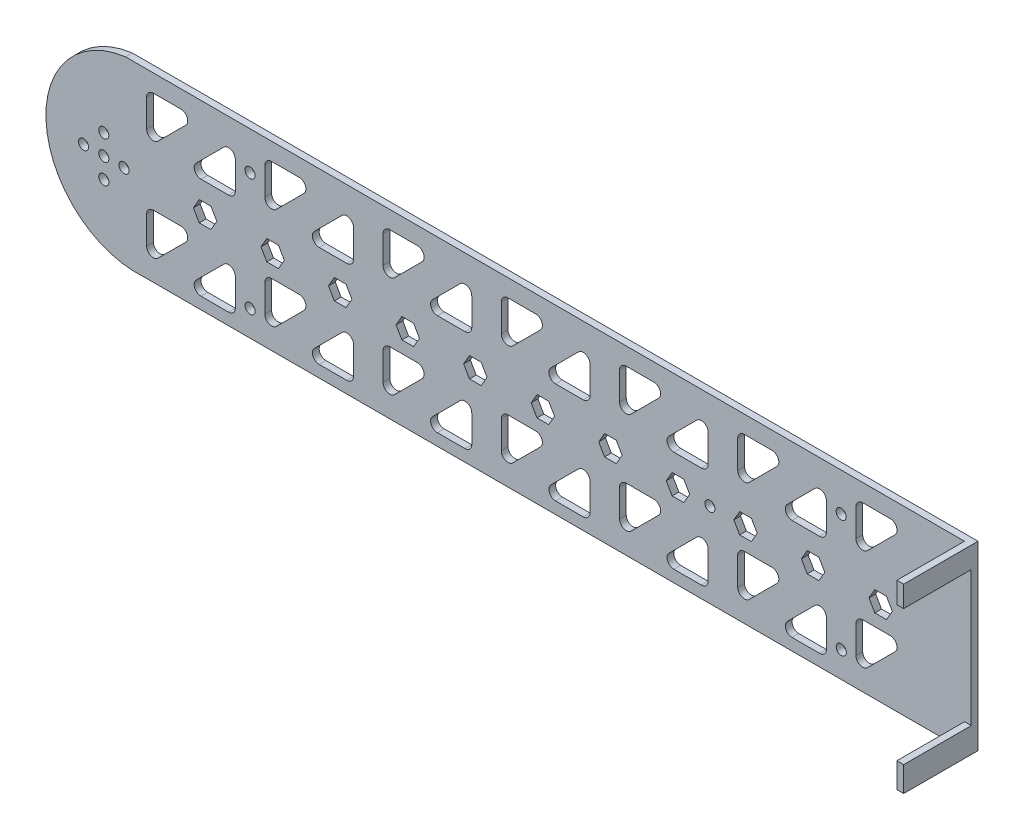
from build123d import *

# Parameters (mm, degrees)
IZIM1_R                     = 1.5
Y_KSEKLIK_EKSTR_ZYON2_DEPTH = 2
IZIM9_R                     = 1.5
KES_EKSTR_ZYON5_DEPTH       = 10
IZIM10_R                    = 1.5
KES_EKSTR_ZYON7_DEPTH       = 10
IZIM11_W                    = 22.917445978
IZIM11_H                    = 53.699619803
KES_EKSTR_ZYON8_DEPTH       = 10
IZIM12_W                    = 2
IZIM12_H                    = 53.699619803
Y_KSEKLIK_EKSTR_ZYON3_DEPTH = 20
KES_EKSTR_ZYON10_DEPTH      = 20


with BuildPart() as part:
    # Çizim1 → Yükseklik-Ekstrüzyon2 (new body)
    with BuildSketch(Plane.XY):
        with BuildLine():
            ThreePointArc((-123.68208832, 28.6803889), (-147.097650837, -0.85979795), (-118.162671893, -25.019230903))
            Line((-118.162671893, -25.019230903), (122.31562704, -25.019230903))
            Line((122.31562704, -25.019230903), (144.746839173, -25.019230903))
            ThreePointArc((144.746839173, -25.019230903), (146.161052735, -24.433444465), (146.746839173, -23.019230903))
            Line((146.746839173, -23.019230903), (146.746839173, -18.118237576))
            Line((146.746839173, -18.118237576), (127.216282083, -18.118237576))
            Line((127.216282083, -18.118237576), (126.706405407, 21.900803601))
            Line((126.706405407, 21.900803601), (146.706405407, 21.900803601))
            Line((146.706405407, 21.900803601), (146.706405407, 26.6803889))
            ThreePointArc((146.706405407, 26.6803889), (146.120618969, 28.094602463), (144.706405407, 28.6803889))
            Line((144.706405407, 28.6803889), (-123.68208832, 28.6803889))
        make_face()
        with BuildLine():
            Line((-117.432950192, -16.684982837), (-117.432950192, -8.513409962))
            ThreePointArc((-117.432950192, -8.513409962), (-116.847163754, -7.099196399), (-115.432950192, -6.513409962))
            Line((-115.432950192, -6.513409962), (-107.261377316, -6.513409962))
            ThreePointArc((-107.261377316, -6.513409962), (-105.413618251, -7.748043097), (-105.847163754, -9.927623524))
            Line((-105.847163754, -9.927623524), (-114.018736629, -18.099196399))
            ThreePointArc((-114.018736629, -18.099196399), (-116.198317056, -18.532741902), (-117.432950192, -16.684982837))
        make_face(mode=Mode.SUBTRACT)
        with BuildLine():
            Line((-102.756511954, -18.099196399), (-94.584939079, -9.927623524))
            ThreePointArc((-94.584939079, -9.927623524), (-92.405358652, -9.494078021), (-91.170725517, -11.341837086))
            Line((-91.170725517, -11.341837086), (-91.170725517, -19.513409962))
            ThreePointArc((-91.170725517, -19.513409962), (-91.756511954, -20.927623524), (-93.170725517, -21.513409962))
            Line((-93.170725517, -21.513409962), (-101.342298392, -21.513409962))
            ThreePointArc((-101.342298392, -21.513409962), (-103.190057457, -20.278776826), (-102.756511954, -18.099196399))
        make_face(mode=Mode.SUBTRACT)
        with BuildLine():
            Line((-82.432950192, -16.684982837), (-82.432950192, -8.513409962))
            ThreePointArc((-82.432950192, -8.513409962), (-81.847163754, -7.099196399), (-80.432950192, -6.513409962))
            Line((-80.432950192, -6.513409962), (-72.261377316, -6.513409962))
            ThreePointArc((-72.261377316, -6.513409962), (-70.413618251, -7.748043097), (-70.847163754, -9.927623524))
            Line((-70.847163754, -9.927623524), (-79.018736629, -18.099196399))
            ThreePointArc((-79.018736629, -18.099196399), (-81.198317056, -18.532741902), (-82.432950192, -16.684982837))
        make_face(mode=Mode.SUBTRACT)
        with BuildLine():
            Line((-67.756511954, -18.099196399), (-59.584939079, -9.927623524))
            ThreePointArc((-59.584939079, -9.927623524), (-57.405358652, -9.494078021), (-56.170725517, -11.341837086))
            Line((-56.170725517, -11.341837086), (-56.170725517, -19.513409962))
            ThreePointArc((-56.170725517, -19.513409962), (-56.756511954, -20.927623524), (-58.170725517, -21.513409962))
            Line((-58.170725517, -21.513409962), (-66.342298392, -21.513409962))
            ThreePointArc((-66.342298392, -21.513409962), (-68.190057457, -20.278776826), (-67.756511954, -18.099196399))
        make_face(mode=Mode.SUBTRACT)
        with BuildLine():
            Line((-47.432950192, -16.684982837), (-47.432950192, -8.513409962))
            ThreePointArc((-47.432950192, -8.513409962), (-46.847163754, -7.099196399), (-45.432950192, -6.513409962))
            Line((-45.432950192, -6.513409962), (-37.261377316, -6.513409962))
            ThreePointArc((-37.261377316, -6.513409962), (-35.413618251, -7.748043097), (-35.847163754, -9.927623524))
            Line((-35.847163754, -9.927623524), (-44.018736629, -18.099196399))
            ThreePointArc((-44.018736629, -18.099196399), (-46.198317056, -18.532741902), (-47.432950192, -16.684982837))
        make_face(mode=Mode.SUBTRACT)
        with BuildLine():
            Line((-32.756511954, -18.099196399), (-24.584939079, -9.927623524))
            ThreePointArc((-24.584939079, -9.927623524), (-22.405358652, -9.494078021), (-21.170725517, -11.341837086))
            Line((-21.170725517, -11.341837086), (-21.170725517, -19.513409962))
            ThreePointArc((-21.170725517, -19.513409962), (-21.756511954, -20.927623524), (-23.170725517, -21.513409962))
            Line((-23.170725517, -21.513409962), (-31.342298392, -21.513409962))
            ThreePointArc((-31.342298392, -21.513409962), (-33.190057457, -20.278776826), (-32.756511954, -18.099196399))
        make_face(mode=Mode.SUBTRACT)
        with BuildLine():
            Line((-12.432950192, -16.684982837), (-12.432950192, -8.513409962))
            ThreePointArc((-12.432950192, -8.513409962), (-11.847163754, -7.099196399), (-10.432950192, -6.513409962))
            Line((-10.432950192, -6.513409962), (-2.261377316, -6.513409962))
            ThreePointArc((-2.261377316, -6.513409962), (-0.413618251, -7.748043097), (-0.847163754, -9.927623524))
            Line((-0.847163754, -9.927623524), (-9.018736629, -18.099196399))
            ThreePointArc((-9.018736629, -18.099196399), (-11.198317056, -18.532741902), (-12.432950192, -16.684982837))
        make_face(mode=Mode.SUBTRACT)
        Polygon((-96.652716692, 0.01885212), (-98.388672632, -2.978889859), (-101.85277131, -2.974378905), (-103.580914048, 0.027874028), (-101.844958108, 3.025616007), (-98.38085943, 3.021105053), align=None, mode=Mode.SUBTRACT)
        Polygon((-76.652716692, 0.01885212), (-78.388672632, -2.978889859), (-81.85277131, -2.974378905), (-83.580914048, 0.027874028), (-81.844958108, 3.025616007), (-78.38085943, 3.021105053), align=None, mode=Mode.SUBTRACT)
        Polygon((-56.652716692, 0.01885212), (-58.388672632, -2.978889859), (-61.85277131, -2.974378905), (-63.580914048, 0.027874028), (-61.844958108, 3.025616007), (-58.38085943, 3.021105053), align=None, mode=Mode.SUBTRACT)
        Polygon((-36.652716692, 0.01885212), (-38.388672632, -2.978889859), (-41.85277131, -2.974378905), (-43.580914048, 0.027874028), (-41.844958108, 3.025616007), (-38.38085943, 3.021105053), align=None, mode=Mode.SUBTRACT)
        Polygon((-16.652716692, 0.01885212), (-18.388672632, -2.978889859), (-21.85277131, -2.974378905), (-23.580914048, 0.027874028), (-21.844958108, 3.025616007), (-18.38085943, 3.021105053), align=None, mode=Mode.SUBTRACT)
        Polygon((3.347283308, 0.01885212), (1.611327368, -2.978889859), (-1.85277131, -2.974378905), (-3.580914048, 0.027874028), (-1.844958108, 3.025616007), (1.61914057, 3.021105053), align=None, mode=Mode.SUBTRACT)
        with BuildLine():
            Line((2.243488046, -18.099196399), (10.415060921, -9.927623524))
            ThreePointArc((10.415060921, -9.927623524), (12.594641348, -9.494078021), (13.829274483, -11.341837086))
            Line((13.829274483, -11.341837086), (13.829274483, -19.513409962))
            ThreePointArc((13.829274483, -19.513409962), (13.243488046, -20.927623524), (11.829274483, -21.513409962))
            Line((11.829274483, -21.513409962), (3.657701608, -21.513409962))
            ThreePointArc((3.657701608, -21.513409962), (1.809942543, -20.278776826), (2.243488046, -18.099196399))
        make_face(mode=Mode.SUBTRACT)
        with BuildLine():
            Line((22.567049808, -16.684982837), (22.567049808, -8.513409962))
            ThreePointArc((22.567049808, -8.513409962), (23.152836246, -7.099196399), (24.567049808, -6.513409962))
            Line((24.567049808, -6.513409962), (32.738622684, -6.513409962))
            ThreePointArc((32.738622684, -6.513409962), (34.586381749, -7.748043097), (34.152836246, -9.927623524))
            Line((34.152836246, -9.927623524), (25.981263371, -18.099196399))
            ThreePointArc((25.981263371, -18.099196399), (23.801682944, -18.532741902), (22.567049808, -16.684982837))
        make_face(mode=Mode.SUBTRACT)
        with BuildLine():
            Line((37.243488046, -18.099196399), (45.415060921, -9.927623524))
            ThreePointArc((45.415060921, -9.927623524), (47.594641348, -9.494078021), (48.829274483, -11.341837086))
            Line((48.829274483, -11.341837086), (48.829274483, -19.513409962))
            ThreePointArc((48.829274483, -19.513409962), (48.243488046, -20.927623524), (46.829274483, -21.513409962))
            Line((46.829274483, -21.513409962), (38.657701608, -21.513409962))
            ThreePointArc((38.657701608, -21.513409962), (36.809942543, -20.278776826), (37.243488046, -18.099196399))
        make_face(mode=Mode.SUBTRACT)
        with BuildLine():
            Line((57.567049808, -16.684982837), (57.567049808, -8.513409962))
            ThreePointArc((57.567049808, -8.513409962), (58.152836246, -7.099196399), (59.567049808, -6.513409962))
            Line((59.567049808, -6.513409962), (67.738622684, -6.513409962))
            ThreePointArc((67.738622684, -6.513409962), (69.586381749, -7.748043097), (69.152836246, -9.927623524))
            Line((69.152836246, -9.927623524), (60.981263371, -18.099196399))
            ThreePointArc((60.981263371, -18.099196399), (58.801682944, -18.532741902), (57.567049808, -16.684982837))
        make_face(mode=Mode.SUBTRACT)
        with Locations((131.859799091, -22.099196399)):
            Circle(IZIM1_R, mode=Mode.SUBTRACT)
        with Locations((141.859799091, -22.099196399)):
            Circle(IZIM1_R, mode=Mode.SUBTRACT)
        with BuildLine():
            Line((72.243488046, -18.099196399), (80.415060921, -9.927623524))
            ThreePointArc((80.415060921, -9.927623524), (82.594641348, -9.494078021), (83.829274483, -11.341837086))
            Line((83.829274483, -11.341837086), (83.829274483, -19.513409962))
            ThreePointArc((83.829274483, -19.513409962), (83.243488046, -20.927623524), (81.829274483, -21.513409962))
            Line((81.829274483, -21.513409962), (73.657701608, -21.513409962))
            ThreePointArc((73.657701608, -21.513409962), (71.809942543, -20.278776826), (72.243488046, -18.099196399))
        make_face(mode=Mode.SUBTRACT)
        with BuildLine():
            Line((92.567049808, -16.684982837), (92.567049808, -8.513409962))
            ThreePointArc((92.567049808, -8.513409962), (93.152836246, -7.099196399), (94.567049808, -6.513409962))
            Line((94.567049808, -6.513409962), (102.738622684, -6.513409962))
            ThreePointArc((102.738622684, -6.513409962), (104.586381749, -7.748043097), (104.152836246, -9.927623524))
            Line((104.152836246, -9.927623524), (95.981263371, -18.099196399))
            ThreePointArc((95.981263371, -18.099196399), (93.801682944, -18.532741902), (92.567049808, -16.684982837))
        make_face(mode=Mode.SUBTRACT)
        Polygon((23.347283308, 0.01885212), (21.611327368, -2.978889859), (18.14722869, -2.974378905), (16.419085952, 0.027874028), (18.155041892, 3.025616007), (21.61914057, 3.021105053), align=None, mode=Mode.SUBTRACT)
        Polygon((43.347283308, 0.01885212), (41.611327368, -2.978889859), (38.14722869, -2.974378905), (36.419085952, 0.027874028), (38.155041892, 3.025616007), (41.61914057, 3.021105053), align=None, mode=Mode.SUBTRACT)
        Polygon((63.347283308, 0.01885212), (61.611327368, -2.978889859), (58.14722869, -2.974378905), (56.419085952, 0.027874028), (58.155041892, 3.025616007), (61.61914057, 3.021105053), align=None, mode=Mode.SUBTRACT)
        Polygon((83.347283308, 0.01885212), (81.611327368, -2.978889859), (78.14722869, -2.974378905), (76.419085952, 0.027874028), (78.155041892, 3.025616007), (81.61914057, 3.021105053), align=None, mode=Mode.SUBTRACT)
        Polygon((103.347283308, 0.01885212), (101.611327368, -2.978889859), (98.14722869, -2.974378905), (96.419085952, 0.027874028), (98.155041892, 3.025616007), (101.61914057, 3.021105053), align=None, mode=Mode.SUBTRACT)
        with BuildLine():
            Line((-102.756511954, 11.900803601), (-94.584939079, 20.072376476))
            ThreePointArc((-94.584939079, 20.072376476), (-92.405358652, 20.505921979), (-91.170725517, 18.658162914))
            Line((-91.170725517, 18.658162914), (-91.170725517, 10.486590038))
            ThreePointArc((-91.170725517, 10.486590038), (-91.756511954, 9.072376476), (-93.170725517, 8.486590038))
            Line((-93.170725517, 8.486590038), (-101.342298392, 8.486590038))
            ThreePointArc((-101.342298392, 8.486590038), (-103.190057457, 9.721223174), (-102.756511954, 11.900803601))
        make_face(mode=Mode.SUBTRACT)
        with BuildLine():
            Line((-67.756511954, 11.900803601), (-59.584939079, 20.072376476))
            ThreePointArc((-59.584939079, 20.072376476), (-57.405358652, 20.505921979), (-56.170725517, 18.658162914))
            Line((-56.170725517, 18.658162914), (-56.170725517, 10.486590038))
            ThreePointArc((-56.170725517, 10.486590038), (-56.756511954, 9.072376476), (-58.170725517, 8.486590038))
            Line((-58.170725517, 8.486590038), (-66.342298392, 8.486590038))
            ThreePointArc((-66.342298392, 8.486590038), (-68.190057457, 9.721223174), (-67.756511954, 11.900803601))
        make_face(mode=Mode.SUBTRACT)
        with BuildLine():
            Line((-32.756511954, 11.900803601), (-24.584939079, 20.072376476))
            ThreePointArc((-24.584939079, 20.072376476), (-22.405358652, 20.505921979), (-21.170725517, 18.658162914))
            Line((-21.170725517, 18.658162914), (-21.170725517, 10.486590038))
            ThreePointArc((-21.170725517, 10.486590038), (-21.756511954, 9.072376476), (-23.170725517, 8.486590038))
            Line((-23.170725517, 8.486590038), (-31.342298392, 8.486590038))
            ThreePointArc((-31.342298392, 8.486590038), (-33.190057457, 9.721223174), (-32.756511954, 11.900803601))
        make_face(mode=Mode.SUBTRACT)
        with BuildLine():
            Line((-117.432950192, 13.315017163), (-117.432950192, 21.486590038))
            ThreePointArc((-117.432950192, 21.486590038), (-116.847163754, 22.900803601), (-115.432950192, 23.486590038))
            Line((-115.432950192, 23.486590038), (-107.261377316, 23.486590038))
            ThreePointArc((-107.261377316, 23.486590038), (-105.413618251, 22.251956903), (-105.847163754, 20.072376476))
            Line((-105.847163754, 20.072376476), (-114.018736629, 11.900803601))
            ThreePointArc((-114.018736629, 11.900803601), (-116.198317056, 11.467258098), (-117.432950192, 13.315017163))
        make_face(mode=Mode.SUBTRACT)
        with BuildLine():
            Line((-82.432950192, 13.315017163), (-82.432950192, 21.486590038))
            ThreePointArc((-82.432950192, 21.486590038), (-81.847163754, 22.900803601), (-80.432950192, 23.486590038))
            Line((-80.432950192, 23.486590038), (-72.261377316, 23.486590038))
            ThreePointArc((-72.261377316, 23.486590038), (-70.413618251, 22.251956903), (-70.847163754, 20.072376476))
            Line((-70.847163754, 20.072376476), (-79.018736629, 11.900803601))
            ThreePointArc((-79.018736629, 11.900803601), (-81.198317056, 11.467258098), (-82.432950192, 13.315017163))
        make_face(mode=Mode.SUBTRACT)
        with BuildLine():
            Line((-47.432950192, 13.315017163), (-47.432950192, 21.486590038))
            ThreePointArc((-47.432950192, 21.486590038), (-46.847163754, 22.900803601), (-45.432950192, 23.486590038))
            Line((-45.432950192, 23.486590038), (-37.261377316, 23.486590038))
            ThreePointArc((-37.261377316, 23.486590038), (-35.413618251, 22.251956903), (-35.847163754, 20.072376476))
            Line((-35.847163754, 20.072376476), (-44.018736629, 11.900803601))
            ThreePointArc((-44.018736629, 11.900803601), (-46.198317056, 11.467258098), (-47.432950192, 13.315017163))
        make_face(mode=Mode.SUBTRACT)
        with BuildLine():
            Line((-12.432950192, 13.315017163), (-12.432950192, 21.486590038))
            ThreePointArc((-12.432950192, 21.486590038), (-11.847163754, 22.900803601), (-10.432950192, 23.486590038))
            Line((-10.432950192, 23.486590038), (-2.261377316, 23.486590038))
            ThreePointArc((-2.261377316, 23.486590038), (-0.413618251, 22.251956903), (-0.847163754, 20.072376476))
            Line((-0.847163754, 20.072376476), (-9.018736629, 11.900803601))
            ThreePointArc((-9.018736629, 11.900803601), (-11.198317056, 11.467258098), (-12.432950192, 13.315017163))
        make_face(mode=Mode.SUBTRACT)
        with BuildLine():
            Line((2.243488046, 11.900803601), (10.415060921, 20.072376476))
            ThreePointArc((10.415060921, 20.072376476), (12.594641348, 20.505921979), (13.829274483, 18.658162914))
            Line((13.829274483, 18.658162914), (13.829274483, 10.486590038))
            ThreePointArc((13.829274483, 10.486590038), (13.243488046, 9.072376476), (11.829274483, 8.486590038))
            Line((11.829274483, 8.486590038), (3.657701608, 8.486590038))
            ThreePointArc((3.657701608, 8.486590038), (1.809942543, 9.721223174), (2.243488046, 11.900803601))
        make_face(mode=Mode.SUBTRACT)
        with BuildLine():
            Line((37.243488046, 11.900803601), (45.415060921, 20.072376476))
            ThreePointArc((45.415060921, 20.072376476), (47.594641348, 20.505921979), (48.829274483, 18.658162914))
            Line((48.829274483, 18.658162914), (48.829274483, 10.486590038))
            ThreePointArc((48.829274483, 10.486590038), (48.243488046, 9.072376476), (46.829274483, 8.486590038))
            Line((46.829274483, 8.486590038), (38.657701608, 8.486590038))
            ThreePointArc((38.657701608, 8.486590038), (36.809942543, 9.721223174), (37.243488046, 11.900803601))
        make_face(mode=Mode.SUBTRACT)
        with BuildLine():
            Line((72.243488046, 11.900803601), (80.415060921, 20.072376476))
            ThreePointArc((80.415060921, 20.072376476), (82.594641348, 20.505921979), (83.829274483, 18.658162914))
            Line((83.829274483, 18.658162914), (83.829274483, 10.486590038))
            ThreePointArc((83.829274483, 10.486590038), (83.243488046, 9.072376476), (81.829274483, 8.486590038))
            Line((81.829274483, 8.486590038), (73.657701608, 8.486590038))
            ThreePointArc((73.657701608, 8.486590038), (71.809942543, 9.721223174), (72.243488046, 11.900803601))
        make_face(mode=Mode.SUBTRACT)
        with BuildLine():
            Line((22.567049808, 13.315017163), (22.567049808, 21.486590038))
            ThreePointArc((22.567049808, 21.486590038), (23.152836246, 22.900803601), (24.567049808, 23.486590038))
            Line((24.567049808, 23.486590038), (32.738622684, 23.486590038))
            ThreePointArc((32.738622684, 23.486590038), (34.586381749, 22.251956903), (34.152836246, 20.072376476))
            Line((34.152836246, 20.072376476), (25.981263371, 11.900803601))
            ThreePointArc((25.981263371, 11.900803601), (23.801682944, 11.467258098), (22.567049808, 13.315017163))
        make_face(mode=Mode.SUBTRACT)
        with BuildLine():
            Line((57.567049808, 13.315017163), (57.567049808, 21.486590038))
            ThreePointArc((57.567049808, 21.486590038), (58.152836246, 22.900803601), (59.567049808, 23.486590038))
            Line((59.567049808, 23.486590038), (67.738622684, 23.486590038))
            ThreePointArc((67.738622684, 23.486590038), (69.586381749, 22.251956903), (69.152836246, 20.072376476))
            Line((69.152836246, 20.072376476), (60.981263371, 11.900803601))
            ThreePointArc((60.981263371, 11.900803601), (58.801682944, 11.467258098), (57.567049808, 13.315017163))
        make_face(mode=Mode.SUBTRACT)
        with BuildLine():
            Line((92.567049808, 13.315017163), (92.567049808, 21.486590038))
            ThreePointArc((92.567049808, 21.486590038), (93.152836246, 22.900803601), (94.567049808, 23.486590038))
            Line((94.567049808, 23.486590038), (102.738622684, 23.486590038))
            ThreePointArc((102.738622684, 23.486590038), (104.586381749, 22.251956903), (104.152836246, 20.072376476))
            Line((104.152836246, 20.072376476), (95.981263371, 11.900803601))
            ThreePointArc((95.981263371, 11.900803601), (93.801682944, 11.467258098), (92.567049808, 13.315017163))
        make_face(mode=Mode.SUBTRACT)
        with Locations((131.859799091, 25.900803601)):
            Circle(IZIM1_R, mode=Mode.SUBTRACT)
        with Locations((141.859799091, 25.900803601)):
            Circle(IZIM1_R, mode=Mode.SUBTRACT)
        with Locations((-130.106258095, 6.023363074)):
            Circle(IZIM1_R, mode=Mode.SUBTRACT)
        with Locations((-130.106258095, -5.976636926)):
            Circle(IZIM1_R, mode=Mode.SUBTRACT)
        with Locations((-136.106258095, 0.023363074)):
            Circle(IZIM1_R, mode=Mode.SUBTRACT)
        with Locations((-130.106258095, 0.023363074)):
            Circle(IZIM1_R, mode=Mode.SUBTRACT)
        with Locations((-124.106258095, 0.023363074)):
            Circle(IZIM1_R, mode=Mode.SUBTRACT)
    extrude(amount=Y_KSEKLIK_EKSTR_ZYON2_DEPTH)

    # Çizim9 → Kes-Ekstrüzyon5 (cut)
    with BuildSketch(Plane(origin=(0, 0, 0), x_dir=(-1, 0, 0), z_dir=(0, 0, -1))):
        with Locations((-88.198162146, 17.400803601)):
            Circle(IZIM9_R)
        with Locations((-88.222150893, -17.356386837)):
            Circle(IZIM9_R)
        with Locations((86.801837854, 17.400803601)):
            Circle(IZIM9_R)
        with Locations((86.777849107, -17.356386837)):
            Circle(IZIM9_R)
    extrude(amount=-KES_EKSTR_ZYON5_DEPTH, mode=Mode.SUBTRACT)

    # Çizim10 → Kes-Ekstrüzyon7 (cut)
    with BuildSketch(Plane.XY.offset(2)):
        with Locations((49.347283308, 0)):
            Circle(IZIM10_R)
    extrude(amount=-KES_EKSTR_ZYON7_DEPTH, mode=Mode.SUBTRACT)

    # Çizim11 → Kes-Ekstrüzyon8 (cut)
    with BuildSketch(Plane.XY.offset(2)):
        with Locations((138.165128396, 1.830578999)):
            Rectangle(IZIM11_W, IZIM11_H)
    extrude(amount=-KES_EKSTR_ZYON8_DEPTH, mode=Mode.SUBTRACT)

    # Çizim12 → Yükseklik-Ekstrüzyon3 (add)
    with BuildSketch(Plane.XY.offset(2)):
        with Locations((125.706405407, 1.830578999)):
            Rectangle(IZIM12_W, IZIM12_H)
    extrude(amount=Y_KSEKLIK_EKSTR_ZYON3_DEPTH)

    # Çizim13 → Kes-Ekstrüzyon10 (cut)
    with BuildSketch(Plane(origin=(126.706405407, 0, 0), x_dir=(0, 0, -1), z_dir=(1, 0, 0))):
        Polygon((-22, 2.407950672), (-22, -17.592049328), (-2, -17.592049328), (-2, 2.407950672), (-2, 22.407950672), (-22, 22.407950672), align=None)
    extrude(amount=-KES_EKSTR_ZYON10_DEPTH, mode=Mode.SUBTRACT)


solid = part.part
